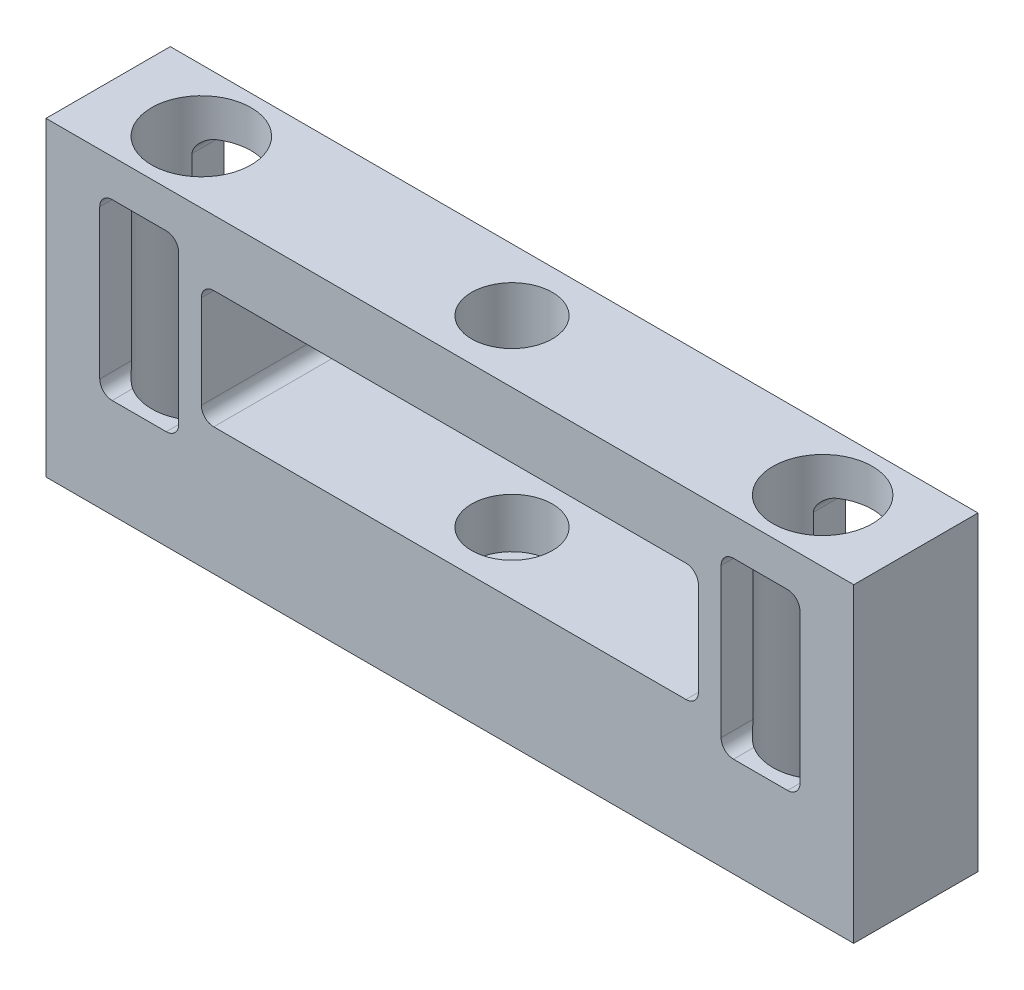
from build123d import *

# Parameters (mm, degrees)
BOSS_EXTRUDE1_DEPTH      = 10
BOSS_EXTRUDE1_DEPTH_BACK = 10
SKETCH1_W                = 130
SKETCH1_H                = 50
CUT_EXTRUDE1_DEPTH       = 83.613558209
CUT_EXTRUDE1_DEPTH_BACK  = 83.613558209
SKETCH2_R                = 8
CUT_EXTRUDE2_DEPTH       = 23
CUT_EXTRUDE3_DEPTH       = 83.613558282
CUT_EXTRUDE3_DEPTH_BACK  = 83.613558282
SKETCH5_R                = 4
SKETCH6_R                = 6.5
CUT_EXTRUDE4_DEPTH       = 37.5


with BuildPart() as part:
    # Sketch1 → Boss-Extrude1 (new, two sides: drawn at the far end of the back side and taken through both)
    with BuildSketch(Plane.XY.offset(-BOSS_EXTRUDE1_DEPTH_BACK)):
        with Locations((0, -5)):
            Rectangle(SKETCH1_W, SKETCH1_H)
        with BuildLine():
            Line((38, 9.5), (-38, 9.5))
            ThreePointArc((-38, 9.5), (-39.414213562, 8.914213562), (-40, 7.5))
            Line((-40, 7.5), (-40, -7.5))
            ThreePointArc((-40, -7.5), (-39.414213562, -8.914213562), (-38, -9.5))
            Line((-38, -9.5), (38, -9.5))
            ThreePointArc((38, -9.5), (39.414213562, -8.914213562), (40, -7.5))
            Line((40, -7.5), (40, 7.5))
            ThreePointArc((40, 7.5), (39.414213562, 8.914213562), (38, 9.5))
        make_face(mode=Mode.SUBTRACT)
    extrude(amount=BOSS_EXTRUDE1_DEPTH + BOSS_EXTRUDE1_DEPTH_BACK)

    # Sketch2 → Cut-Extrude1 (cut, two sides: drawn at the far end of the back side and taken through both)
    with BuildSketch(Plane(origin=(0, 20, 0), x_dir=(1, 0, 0), z_dir=(0, 1, 0)).offset(-CUT_EXTRUDE1_DEPTH_BACK)):
        with Locations((-50, 0)):
            Circle(SKETCH2_R)
        with Locations((50, 0)):
            Circle(SKETCH2_R)
    extrude(amount=CUT_EXTRUDE1_DEPTH + CUT_EXTRUDE1_DEPTH_BACK, mode=Mode.SUBTRACT)

    # Sketch4 → Cut-Extrude2 (cut)
    with BuildSketch(Plane(origin=(0, 0, -10), x_dir=(-1, 0, 0), z_dir=(0, 0, -1))):
        with BuildLine():
            Line((-45.65, 14), (-54.35, 14))
            ThreePointArc((-54.35, 14), (-55.764213562, 13.414213562), (-56.35, 12))
            Line((-56.35, 12), (-56.35, -12))
            ThreePointArc((-56.35, -12), (-55.764213562, -13.414213562), (-54.35, -14))
            Line((-54.35, -14), (-45.65, -14))
            ThreePointArc((-45.65, -14), (-44.235786438, -13.414213562), (-43.65, -12))
            Line((-43.65, -12), (-43.65, 12))
            ThreePointArc((-43.65, 12), (-44.235786438, 13.414213562), (-45.65, 14))
        make_face()
        with BuildLine():
            Line((56.35, 12), (56.35, -12))
            ThreePointArc((56.35, -12), (55.764213562, -13.414213562), (54.35, -14))
            Line((54.35, -14), (45.65, -14))
            ThreePointArc((45.65, -14), (44.235786438, -13.414213562), (43.65, -12))
            Line((43.65, -12), (43.65, 12))
            ThreePointArc((43.65, 12), (44.235786438, 13.414213562), (45.65, 14))
            Line((45.65, 14), (54.35, 14))
            ThreePointArc((54.35, 14), (55.764213562, 13.414213562), (56.35, 12))
        make_face()
    extrude(amount=-CUT_EXTRUDE2_DEPTH, mode=Mode.SUBTRACT)

    # Sketch5 → Cut-Extrude3 (cut, two sides: drawn at the far end of the back side and taken through both)
    with BuildSketch(Plane(origin=(0, 20, 0), x_dir=(1, 0, 0), z_dir=(0, 1, 0)).offset(-CUT_EXTRUDE3_DEPTH_BACK)):
        Circle(SKETCH5_R)
    extrude(amount=CUT_EXTRUDE3_DEPTH + CUT_EXTRUDE3_DEPTH_BACK, mode=Mode.SUBTRACT)

    # Sketch6 → Cut-Extrude4 (cut)
    with BuildSketch(Plane(origin=(0, 20, 0), x_dir=(1, 0, 0), z_dir=(0, 1, 0))):
        Circle(SKETCH6_R)
    extrude(amount=-CUT_EXTRUDE4_DEPTH, mode=Mode.SUBTRACT)


solid = part.part
